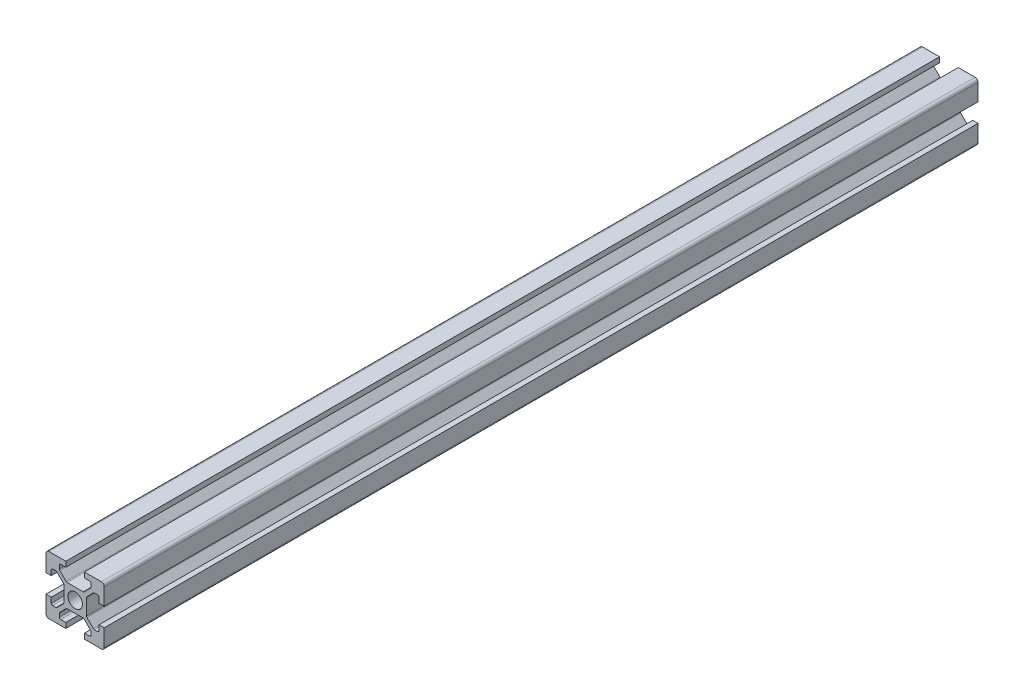
from build123d import *

# Parameters (mm, degrees)
SKETCH1_R           = 2.5
BOSS_EXTRUDE1_DEPTH = 300
FILLET1_R           = 1
FILLET2_R           = 0.5
FILLET3_R           = 0.5
FILLET4_R           = 0.5
FILLET5_R           = 0.5


with BuildPart() as part:
    # Sketch1 → Boss-Extrude1 (new body)
    with BuildSketch(Plane.XY):
        Polygon((13.2, 0), (13.2, 1.8), (15.45, 1.8), (15.45, 3.6), (12.95, 6.1), (7.05, 6.1), (4.55, 3.6), (4.55, 1.8), (6.8, 1.8), (6.8, 0), (0, 0), (0, 6.8), (1.8, 6.8), (1.8, 4.55), (3.6, 4.55), (6.1, 7.05), (6.1, 12.95), (3.6, 15.45), (1.8, 15.45), (1.8, 13.2), (0, 13.2), (0, 20), (6.8, 20), (6.8, 18.2), (4.55, 18.2), (4.55, 16.4), (7.05, 13.9), (12.95, 13.9), (15.45, 16.4), (15.45, 18.2), (13.2, 18.2), (13.2, 20), (20, 20), (20, 13.2), (18.2, 13.2), (18.2, 15.45), (16.4, 15.45), (13.9, 12.95), (13.9, 7.05), (16.4, 4.55), (18.2, 4.55), (18.2, 6.8), (20, 6.8), (20, 0), align=None)
        with Locations((10, 10)):
            Circle(SKETCH1_R, mode=Mode.SUBTRACT)
    extrude(amount=BOSS_EXTRUDE1_DEPTH)

    # Fillet1
    fillet1_edges = [part.edges().sort_by_distance(p)[0] for p in [
        (0, 0, 150),
        (0, 20, 150),
        (20, 20, 150),
        (20, 0, 150),
    ]]
    fillet(fillet1_edges, radius=FILLET1_R)

    # Fillet2
    fillet2_edges = [part.edges().sort_by_distance(p)[0] for p in [
        (4.55, 18.2, 150),
        (4.55, 16.4, 150),
        (7.05, 13.9, 150),
        (12.95, 13.9, 150),
        (15.45, 16.4, 150),
        (15.45, 18.2, 150),
    ]]
    fillet(fillet2_edges, radius=FILLET2_R)

    # Fillet3
    fillet3_edges = [part.edges().sort_by_distance(p)[0] for p in [
        (18.2, 15.45, 150),
        (16.4, 15.45, 150),
        (13.9, 12.95, 150),
        (13.9, 7.05, 150),
        (16.4, 4.55, 150),
        (18.2, 4.55, 150),
    ]]
    fillet(fillet3_edges, radius=FILLET3_R)

    # Fillet4
    fillet4_edges = [part.edges().sort_by_distance(p)[0] for p in [
        (1.8, 4.55, 150),
        (3.6, 4.55, 150),
        (6.1, 7.05, 150),
        (6.1, 12.95, 150),
        (3.6, 15.45, 150),
        (1.8, 15.45, 150),
    ]]
    fillet(fillet4_edges, radius=FILLET4_R)

    # Fillet5
    fillet5_edges = [part.edges().sort_by_distance(p)[0] for p in [
        (15.45, 1.8, 150),
        (15.45, 3.6, 150),
        (12.95, 6.1, 150),
        (7.05, 6.1, 150),
        (4.55, 3.6, 150),
        (4.55, 1.8, 150),
    ]]
    fillet(fillet5_edges, radius=FILLET5_R)


solid = part.part
